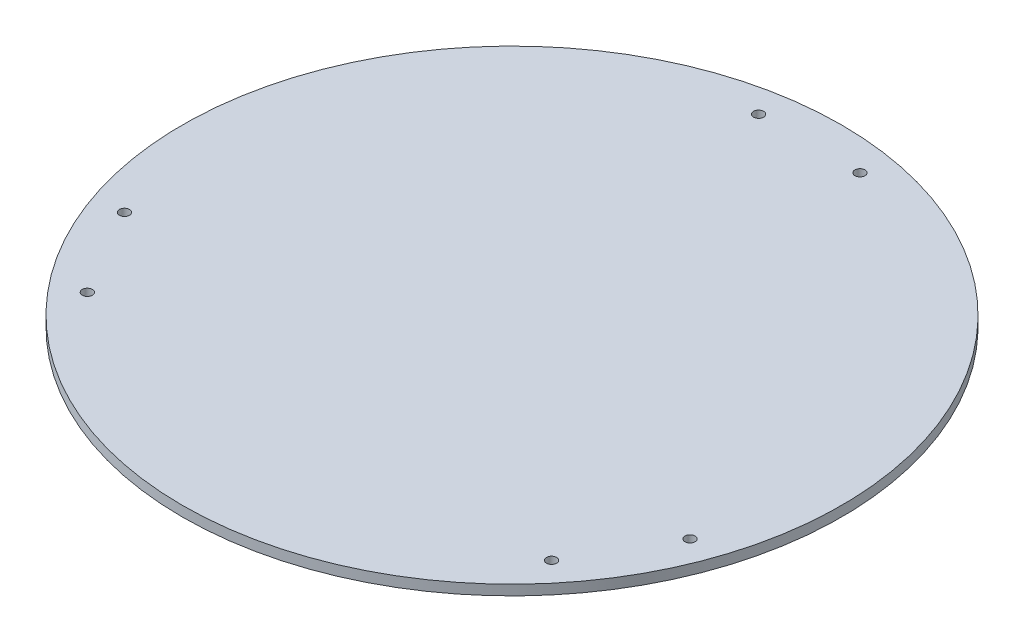
from build123d import *

# Parameters (mm, degrees)
SKETCH1_R           = 65
SKETCH1_R_2         = 1
BOSS_EXTRUDE1_DEPTH = 2


with BuildPart() as part:
    # Sketch1 → Boss-Extrude1 (new body)
    with BuildSketch(Plane(origin=(0, 0, 0), x_dir=(1, 0, 0), z_dir=(0, 1, 0))):
        Circle(SKETCH1_R)
        with Locations((-10, 58.633355695)):
            Circle(SKETCH1_R_2, mode=Mode.SUBTRACT)
        with Locations((10, 58.633355695)):
            Circle(SKETCH1_R_2, mode=Mode.SUBTRACT)
        with Locations((55.777975541, -20.656423809)):
            Circle(SKETCH1_R_2, mode=Mode.SUBTRACT)
        with Locations((45.777975541, -37.976931885)):
            Circle(SKETCH1_R_2, mode=Mode.SUBTRACT)
        with Locations((-45.777975541, -37.976931885)):
            Circle(SKETCH1_R_2, mode=Mode.SUBTRACT)
        with Locations((-55.777975541, -20.656423809)):
            Circle(SKETCH1_R_2, mode=Mode.SUBTRACT)
    extrude(amount=BOSS_EXTRUDE1_DEPTH)


solid = part.part
